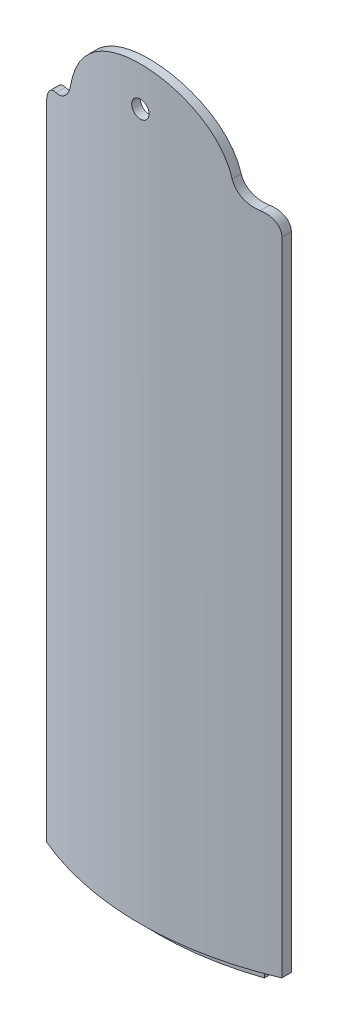
from build123d import *

# Parameters (mm, degrees)
EXTRUDE_1_DEPTH          = 76
EXTRUDE_2_DEPTH          = 2
EXTRUDE_2_DEPTH_BACK     = 76
EXTRUDE_3_DEPTH          = 9.5
CUT_EXTRUDE_1_DEPTH      = 78.5
CUT_EXTRUDE_2_DEPTH      = 4
CUT_EXTRUDE_2_DEPTH_BACK = 78.5
SKETCH_8_R               = 1
CUT_EXTRUDE_3_DEPTH      = 46.5
CUT_EXTRUDE_4_DEPTH      = 2


with BuildPart() as part:
    # Эскиз1 → Бобышка-Вытянуть1 (new body)
    with BuildSketch(Plane(origin=(0, 0, 0), x_dir=(1, 0, 0), z_dir=(0, 1, 0))):
        with BuildLine():
            Line((-13.5, -30.659419434), (-13.5, -31.749015733))
            ThreePointArc((-13.5, -31.749015733), (0, -34.5), (13.5, -31.749015733))
            Line((13.5, -31.749015733), (13.5, -30.659419434))
            ThreePointArc((13.5, -30.659419434), (12.013828707, -31.271679197), (10.5, -31.811947441))
            Line((10.5, -31.811947441), (10.5, -30.757112998))
            ThreePointArc((10.5, -30.757112998), (0, -32.5), (-10.5, -30.757112998))
            Line((-10.5, -30.757112998), (-10.5, -31.811947441))
            ThreePointArc((-10.5, -31.811947441), (-12.013828707, -31.271679197), (-13.5, -30.659419434))
        make_face()
    extrude(amount=EXTRUDE_1_DEPTH)

    # Эскиз2 → Бобышка-Вытянуть2 (add, two sides)
    with BuildSketch(Plane.XZ) as extrude_2_sk:
        with BuildLine():
            Line((-10.5, 31.811947441), (-10.5, 30.757112998))
            Line((-10.5, 30.757112998), (-10.5, 29.69848481))
            ThreePointArc((-10.5, 29.69848481), (0, 31.5), (10.5, 29.69848481))
            Line((10.5, 29.69848481), (10.5, 30.757112998))
            Line((10.5, 30.757112998), (10.5, 31.811947441))
            ThreePointArc((10.5, 31.811947441), (0, 33.5), (-10.5, 31.811947441))
        make_face()
    extrude(amount=EXTRUDE_2_DEPTH)
    extrude(extrude_2_sk.sketch, amount=-EXTRUDE_2_DEPTH_BACK)

    # Эскиз6 → Бобышка-Вытянуть3 (add)
    with BuildSketch(Plane(origin=(0, 76, 0), x_dir=(1, 0, 0), z_dir=(0, 1, 0))):
        with BuildLine():
            Line((-10.5, -30.757112998), (-10.5, -31.811947441))
            ThreePointArc((-10.5, -31.811947441), (-12.013828707, -31.271679197), (-13.5, -30.659419434))
            Line((-13.5, -30.659419434), (-13.5, -31.749015733))
            ThreePointArc((-13.5, -31.749015733), (0, -34.5), (13.5, -31.749015733))
            Line((13.5, -31.749015733), (13.5, -30.659419434))
            ThreePointArc((13.5, -30.659419434), (12.013828707, -31.271679197), (10.5, -31.811947441))
            Line((10.5, -31.811947441), (10.5, -30.757112998))
            ThreePointArc((10.5, -30.757112998), (0, -32.5), (-10.5, -30.757112998))
        make_face()
    extrude(amount=EXTRUDE_3_DEPTH)

    # Эскиз3 → Вырез-Вытянуть1 (cut)
    with BuildSketch(Plane.XY):
        with BuildLine():
            Line((-29.777002316, 76), (-29.777002316, 102.252406504))
            Line((-29.777002316, 102.252406504), (31.597845716, 102.252406504))
            Line((31.597845716, 102.252406504), (31.597845716, 75.705478865))
            Line((31.597845716, 75.705478865), (31.597845716, 73.652327708))
            Line((31.597845716, 73.652327708), (13.5, 73.652327708))
            ThreePointArc((13.5, 73.652327708), (12.995178699, 75.025430995), (11.721154976, 75.744542067))
            ThreePointArc((11.721154976, 75.744542067), (10.143272785, 76.524968738), (9.274814815, 78.056163941))
            ThreePointArc((9.274814815, 78.056163941), (0, 85.5), (-9.274814815, 78.056163941))
            ThreePointArc((-9.274814815, 78.056163941), (-10.143272784, 76.52496874), (-11.721154974, 75.744542071))
            ThreePointArc((-11.721154974, 75.744542071), (-12.995178698, 75.025430999), (-13.5, 73.652327712))
            Line((-13.5, 73.652327712), (-29.777002316, 73.652327712))
            Line((-29.777002316, 73.652327712), (-29.777002316, 76))
        make_face()
    extrude(amount=CUT_EXTRUDE_1_DEPTH, mode=Mode.SUBTRACT)

    # Эскиз7 → Вырез-Вытянуть2 (cut, two sides)
    with BuildSketch(Plane(origin=(0, 76, 0), x_dir=(-1, 0, 0), z_dir=(0, -1, 0))) as cut_extrude_2_sk:
        with BuildLine():
            Line((10.5, -29.69848481), (10.5, -31.811947441))
            ThreePointArc((10.5, -31.811947441), (0, -33.499999909), (-10.5, -31.811947441))
            Line((-10.5, -31.811947441), (-10.5, -29.69848481))
            ThreePointArc((-10.5, -29.69848481), (0, -31.5), (10.5, -29.69848481))
        make_face()
    extrude(amount=CUT_EXTRUDE_2_DEPTH, mode=Mode.SUBTRACT)
    extrude(cut_extrude_2_sk.sketch, amount=-CUT_EXTRUDE_2_DEPTH_BACK, mode=Mode.SUBTRACT)

    # Эскиз8 → Вырез-Вытянуть3 (cut)
    with BuildSketch(Plane.XY):
        with Locations((0, 81)):
            Circle(SKETCH_8_R)
    extrude(amount=CUT_EXTRUDE_3_DEPTH, mode=Mode.SUBTRACT)

    # Эскиз9 → Вырез-Вытянуть4 (cut)
    with BuildSketch(Plane.XZ.offset(2)):
        with BuildLine():
            Line((-10.5, 31.811947426), (-10.5, 30.755216126))
            ThreePointArc((-10.5, 30.755216126), (0, 32.500000073), (10.5, 30.755216126))
            Line((10.5, 30.755216126), (10.5, 31.811947441))
            ThreePointArc((10.5, 31.811947441), (-1e-09, 33.499999996), (-10.5, 31.811947426))
        make_face()
    extrude(amount=-CUT_EXTRUDE_4_DEPTH, mode=Mode.SUBTRACT)


solid = part.part
